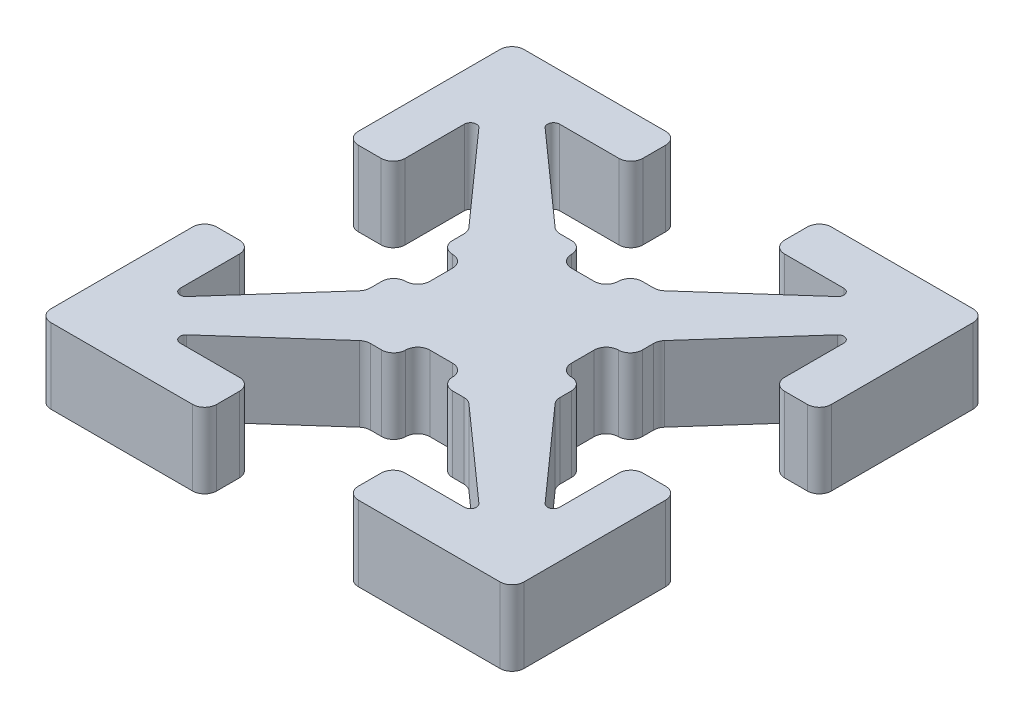
from build123d import *

# Parameters (mm, degrees)
BOSS_EXTRUDE1_DEPTH = 1.5875


with BuildPart() as part:
    # Sketch1 → Boss-Extrude1 (new body)
    with BuildSketch(Plane(origin=(0, 0, 0), x_dir=(1, 0, 0), z_dir=(0, 1, 0))):
        with BuildLine():
            Line((-1.159549536, 2.070936998), (-3.090908521, 3.791368499))
            ThreePointArc((-3.090908521, 3.791368499), (-3.125119474, 3.931396235), (-3.006433754, 4.0132))
            Line((-3.006433754, 4.0132), (-1.7526, 4.0132))
            ThreePointArc((-1.7526, 4.0132), (-1.572994878, 4.087594878), (-1.4986, 4.2672))
            Line((-1.4986, 4.2672), (-1.4986, 4.7498))
            ThreePointArc((-1.4986, 4.7498), (-1.572994878, 4.929405122), (-1.7526, 5.0038))
            Line((-1.7526, 5.0038), (-4.7498, 5.0038))
            ThreePointArc((-4.7498, 5.0038), (-4.929405122, 4.929405122), (-5.0038, 4.7498))
            Line((-5.0038, 4.7498), (-5.0038, 1.7526))
            ThreePointArc((-5.0038, 1.7526), (-4.929405122, 1.572994878), (-4.7498, 1.4986))
            Line((-4.7498, 1.4986), (-4.2672, 1.4986))
            ThreePointArc((-4.2672, 1.4986), (-4.087594878, 1.572994878), (-4.0132, 1.7526))
            Line((-4.0132, 1.7526), (-4.0132, 3.006433754))
            ThreePointArc((-4.0132, 3.006433754), (-3.931396235, 3.125119474), (-3.791368499, 3.090908521))
            Line((-3.791368499, 3.090908521), (-2.070936998, 1.159549536))
            ThreePointArc((-2.070936998, 1.159549536), (-2.023228558, 1.08099247), (-2.0066, 0.9906))
            Line((-2.0066, 0.9906), (-2.0066, 0.7493))
            ThreePointArc((-2.0066, 0.7493), (-1.932205122, 0.569694878), (-1.7526, 0.4953))
            ThreePointArc((-1.7526, 0.4953), (-1.572994878, 0.420905122), (-1.4986, 0.2413))
            Line((-1.4986, 0.2413), (-1.4986, -0.2413))
            ThreePointArc((-1.4986, -0.2413), (-1.572994878, -0.420905122), (-1.7526, -0.4953))
            ThreePointArc((-1.7526, -0.4953), (-1.932205122, -0.569694878), (-2.0066, -0.7493))
            Line((-2.0066, -0.7493), (-2.0066, -0.9906))
            ThreePointArc((-2.0066, -0.9906), (-2.023228558, -1.08099247), (-2.070936998, -1.159549536))
            Line((-2.070936998, -1.159549536), (-3.791368499, -3.090908521))
            ThreePointArc((-3.791368499, -3.090908521), (-3.931396235, -3.125119474), (-4.0132, -3.006433754))
            Line((-4.0132, -3.006433754), (-4.0132, -1.7526))
            ThreePointArc((-4.0132, -1.7526), (-4.087594878, -1.572994878), (-4.2672, -1.4986))
            Line((-4.2672, -1.4986), (-4.7498, -1.4986))
            ThreePointArc((-4.7498, -1.4986), (-4.929405122, -1.572994878), (-5.0038, -1.7526))
            Line((-5.0038, -1.7526), (-5.0038, -4.7498))
            ThreePointArc((-5.0038, -4.7498), (-4.929405122, -4.929405122), (-4.7498, -5.0038))
            Line((-4.7498, -5.0038), (-1.7526, -5.0038))
            ThreePointArc((-1.7526, -5.0038), (-1.572994878, -4.929405122), (-1.4986, -4.7498))
            Line((-1.4986, -4.7498), (-1.4986, -4.2672))
            ThreePointArc((-1.4986, -4.2672), (-1.572994878, -4.087594878), (-1.7526, -4.0132))
            Line((-1.7526, -4.0132), (-3.006433754, -4.0132))
            ThreePointArc((-3.006433754, -4.0132), (-3.125119474, -3.931396235), (-3.090908521, -3.791368499))
            Line((-3.090908521, -3.791368499), (-1.159549536, -2.070936998))
            ThreePointArc((-1.159549536, -2.070936998), (-1.08099247, -2.023228558), (-0.9906, -2.0066))
            Line((-0.9906, -2.0066), (-0.7493, -2.0066))
            ThreePointArc((-0.7493, -2.0066), (-0.569694878, -1.932205122), (-0.4953, -1.7526))
            ThreePointArc((-0.4953, -1.7526), (-0.420905122, -1.572994878), (-0.2413, -1.4986))
            Line((-0.2413, -1.4986), (0.2413, -1.4986))
            ThreePointArc((0.2413, -1.4986), (0.420905122, -1.572994878), (0.4953, -1.7526))
            ThreePointArc((0.4953, -1.7526), (0.569694878, -1.932205122), (0.7493, -2.0066))
            Line((0.7493, -2.0066), (0.9906, -2.0066))
            ThreePointArc((0.9906, -2.0066), (1.08099247, -2.023228558), (1.159549536, -2.070936998))
            Line((1.159549536, -2.070936998), (3.090908521, -3.791368499))
            ThreePointArc((3.090908521, -3.791368499), (3.125119474, -3.931396235), (3.006433754, -4.0132))
            Line((3.006433754, -4.0132), (1.7526, -4.0132))
            ThreePointArc((1.7526, -4.0132), (1.572994878, -4.087594878), (1.4986, -4.2672))
            Line((1.4986, -4.2672), (1.4986, -4.7498))
            ThreePointArc((1.4986, -4.7498), (1.572994878, -4.929405122), (1.7526, -5.0038))
            Line((1.7526, -5.0038), (4.7498, -5.0038))
            ThreePointArc((4.7498, -5.0038), (4.929405122, -4.929405122), (5.0038, -4.7498))
            Line((5.0038, -4.7498), (5.0038, -1.7526))
            ThreePointArc((5.0038, -1.7526), (4.929405122, -1.572994878), (4.7498, -1.4986))
            Line((4.7498, -1.4986), (4.2672, -1.4986))
            ThreePointArc((4.2672, -1.4986), (4.087594878, -1.572994878), (4.0132, -1.7526))
            Line((4.0132, -1.7526), (4.0132, -3.006433754))
            ThreePointArc((4.0132, -3.006433754), (3.931396235, -3.125119474), (3.791368499, -3.090908521))
            Line((3.791368499, -3.090908521), (2.070936998, -1.159549536))
            ThreePointArc((2.070936998, -1.159549536), (2.023228558, -1.08099247), (2.0066, -0.9906))
            Line((2.0066, -0.9906), (2.0066, -0.7493))
            ThreePointArc((2.0066, -0.7493), (1.932205122, -0.569694878), (1.7526, -0.4953))
            ThreePointArc((1.7526, -0.4953), (1.572994878, -0.420905122), (1.4986, -0.2413))
            Line((1.4986, -0.2413), (1.4986, 0.2413))
            ThreePointArc((1.4986, 0.2413), (1.572994878, 0.420905122), (1.7526, 0.4953))
            ThreePointArc((1.7526, 0.4953), (1.932205122, 0.569694878), (2.0066, 0.7493))
            Line((2.0066, 0.7493), (2.0066, 0.9906))
            ThreePointArc((2.0066, 0.9906), (2.023228558, 1.08099247), (2.070936998, 1.159549536))
            Line((2.070936998, 1.159549536), (3.791368499, 3.090908521))
            ThreePointArc((3.791368499, 3.090908521), (3.931396235, 3.125119474), (4.0132, 3.006433754))
            Line((4.0132, 3.006433754), (4.0132, 1.7526))
            ThreePointArc((4.0132, 1.7526), (4.087594878, 1.572994878), (4.2672, 1.4986))
            Line((4.2672, 1.4986), (4.7498, 1.4986))
            ThreePointArc((4.7498, 1.4986), (4.929405122, 1.572994878), (5.0038, 1.7526))
            Line((5.0038, 1.7526), (5.0038, 4.7498))
            ThreePointArc((5.0038, 4.7498), (4.929405122, 4.929405122), (4.7498, 5.0038))
            Line((4.7498, 5.0038), (1.7526, 5.0038))
            ThreePointArc((1.7526, 5.0038), (1.572994878, 4.929405122), (1.4986, 4.7498))
            Line((1.4986, 4.7498), (1.4986, 4.2672))
            ThreePointArc((1.4986, 4.2672), (1.572994878, 4.087594878), (1.7526, 4.0132))
            Line((1.7526, 4.0132), (3.006433754, 4.0132))
            ThreePointArc((3.006433754, 4.0132), (3.125119474, 3.931396235), (3.090908521, 3.791368499))
            Line((3.090908521, 3.791368499), (1.159549536, 2.070936998))
            ThreePointArc((1.159549536, 2.070936998), (1.08099247, 2.023228558), (0.9906, 2.0066))
            Line((0.9906, 2.0066), (0.7493, 2.0066))
            ThreePointArc((0.7493, 2.0066), (0.569694878, 1.932205122), (0.4953, 1.7526))
            ThreePointArc((0.4953, 1.7526), (0.420905122, 1.572994878), (0.2413, 1.4986))
            Line((0.2413, 1.4986), (-0.2413, 1.4986))
            ThreePointArc((-0.2413, 1.4986), (-0.420905122, 1.572994878), (-0.4953, 1.7526))
            ThreePointArc((-0.4953, 1.7526), (-0.569694878, 1.932205122), (-0.7493, 2.0066))
            Line((-0.7493, 2.0066), (-0.9906, 2.0066))
            ThreePointArc((-0.9906, 2.0066), (-1.08099247, 2.023228558), (-1.159549536, 2.070936998))
        make_face()
    extrude(amount=BOSS_EXTRUDE1_DEPTH)


solid = part.part
